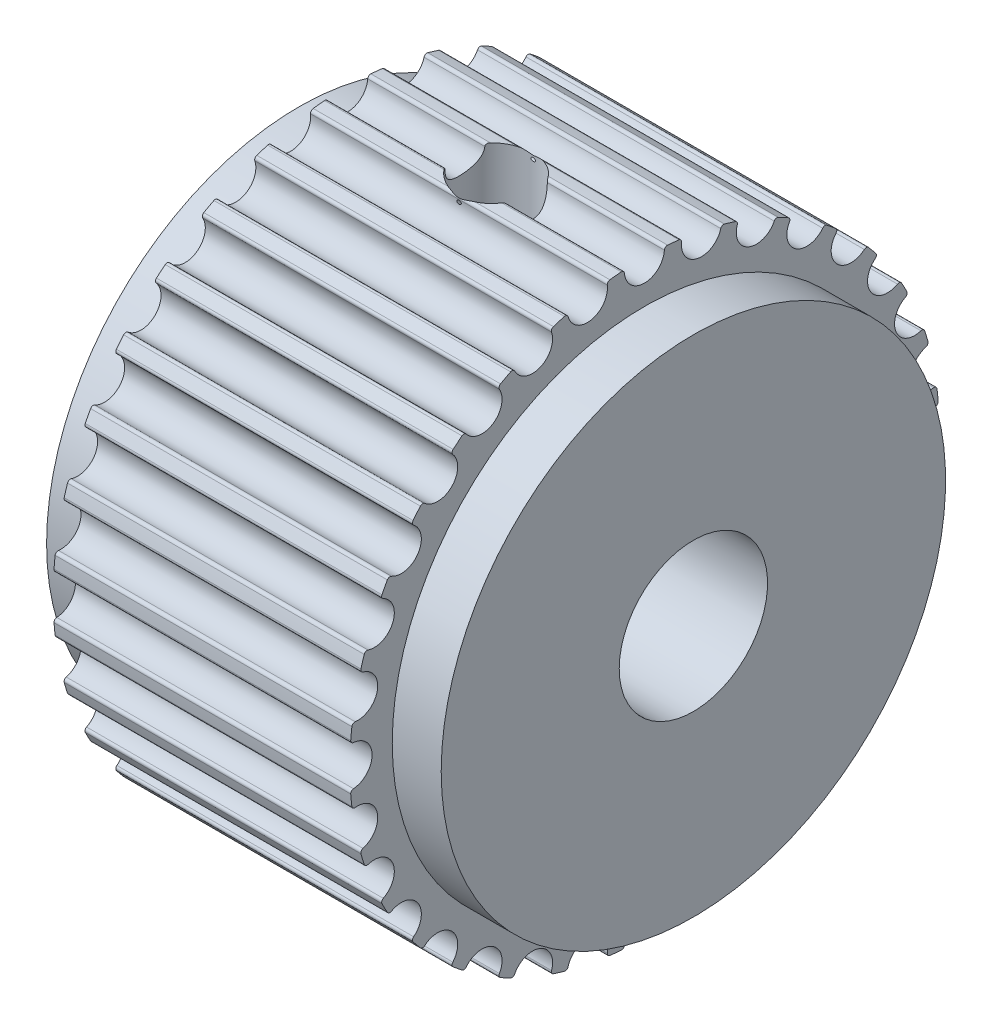
from build123d import *

# Parameters (mm, degrees)
CUT_EXTRUDE1_DEPTH       = 19.246432528
FILLET1_R                = 0.1
CIRPATTERN1_COUNT        = 32
FILLET1_OF_CIRPATTERN1_R = 0.1
TAPPED_HOLE1_REACH       = 42.167
TAPPED_HOLE1_BORE_R      = 1.25
CIRPATTERN2_COUNT        = 2
CIRPATTERN2_ANGLE        = 120


with BuildPart() as part:
    # Sketch1 → Revolve1 (revolve)
    with BuildSketch(Plane.XY, mode=Mode.PRIVATE) as revolve1_sk:
        Polygon((1.65, 9.93), (11.65, 9.93), (11.65, 8.5), (13.3, 8.5), (13.3, 2.5), (0, 2.5), (0, 8.5), (1.65, 8.5), align=None)
    revolve(revolve1_sk.sketch.rotate(Axis((0, 0, 0), (1, 0, 0)), 90), axis=Axis((0, 0, 0), (1, 0, 0)))

    # Sketch2 → Cut-Extrude1 (cut, through all)
    with BuildSketch(Plane(origin=(1.65, 0, 0), x_dir=(0, 0, -1), z_dir=(1, 0, 0))):
        with BuildLine():
            ThreePointArc((0.672980981, 9.90716895), (0, 9.93), (-0.672980981, 9.90716895))
            ThreePointArc((-0.672980981, 9.90716895), (0, 9.18), (0.672980981, 9.90716895))
        make_face()
    cut_extrude1 = extrude(amount=CUT_EXTRUDE1_DEPTH, mode=Mode.SUBTRACT)

    # Fillet1
    fillet1_edges = [part.edges().sort_by_distance(p)[0] for p in [
        (6.65, 9.90716895, 0.672980981),
        (6.65, 9.90716895, -0.672980981),
    ]]
    fillet(fillet1_edges, radius=FILLET1_R)

    # CirPattern1: Cut-Extrude1 ×32 about axis
    cirpattern1_axis = Axis((0, 0, 0), (1, 0, 0))
    for i in range(1, CIRPATTERN1_COUNT):
        add(cut_extrude1.rotate(cirpattern1_axis, i * 360 / CIRPATTERN1_COUNT), mode=Mode.SUBTRACT)

    # Fillet1 of CirPattern1
    fillet1_of_cirpattern1_edges = [part.edges().sort_by_distance(p)[0] for p in [
        (6.65, 9.5855134, 2.592842621),
        (6.65, 9.848097553, 1.272742941),
        (6.65, 8.895491946, 4.413062773),
        (6.65, 9.41056929, 3.169556065),
        (6.65, 7.863621725, 6.063691397),
        (6.65, 8.611398126, 4.944564927),
        (6.65, 6.529556932, 7.481295762),
        (6.65, 7.481295762, 6.529556932),
        (6.65, 4.944564927, 8.611398126),
        (6.65, 6.063691397, 7.863621725),
        (6.65, 3.169556065, 9.41056929),
        (6.65, 4.413062773, 8.895491946),
        (6.65, 1.272742941, 9.848097553),
        (6.65, 2.592842621, 9.5855134),
        (6.65, -0.672980981, 9.90716895),
        (6.65, 0.672980981, 9.90716895),
        (6.65, -2.592842621, 9.5855134),
        (6.65, -1.272742941, 9.848097553),
        (6.65, -4.413062773, 8.895491946),
        (6.65, -3.169556065, 9.41056929),
        (6.65, -6.063691397, 7.863621725),
        (6.65, -4.944564927, 8.611398126),
        (6.65, -7.481295762, 6.529556932),
        (6.65, -6.529556932, 7.481295762),
        (6.65, -8.611398126, 4.944564927),
        (6.65, -7.863621725, 6.063691397),
        (6.65, -9.41056929, 3.169556065),
        (6.65, -8.895491946, 4.413062773),
        (6.65, -9.848097553, 1.272742941),
        (6.65, -9.5855134, 2.592842621),
        (6.65, -9.90716895, -0.672980981),
        (6.65, -9.90716895, 0.672980981),
        (6.65, -9.5855134, -2.592842621),
        (6.65, -9.848097553, -1.272742941),
        (6.65, -8.895491946, -4.413062773),
        (6.65, -9.41056929, -3.169556065),
        (6.65, -7.863621725, -6.063691397),
        (6.65, -8.611398126, -4.944564927),
        (6.65, -6.529556932, -7.481295762),
        (6.65, -7.481295762, -6.529556932),
        (6.65, -4.944564927, -8.611398126),
        (6.65, -6.063691397, -7.863621725),
        (6.65, -3.169556065, -9.41056929),
        (6.65, -4.413062773, -8.895491946),
        (6.65, -1.272742941, -9.848097553),
        (6.65, -2.592842621, -9.5855134),
        (6.65, 0.672980981, -9.90716895),
        (6.65, -0.672980981, -9.90716895),
        (6.65, 2.592842621, -9.5855134),
        (6.65, 1.272742941, -9.848097553),
        (6.65, 4.413062773, -8.895491946),
        (6.65, 3.169556065, -9.41056929),
        (6.65, 6.063691397, -7.863621725),
        (6.65, 4.944564927, -8.611398126),
        (6.65, 7.481295762, -6.529556932),
        (6.65, 6.529556932, -7.481295762),
        (6.65, 8.611398126, -4.944564927),
        (6.65, 7.863621725, -6.063691397),
        (6.65, 9.41056929, -3.169556065),
        (6.65, 8.895491946, -4.413062773),
        (6.65, 9.848097553, -1.272742941),
        (6.65, 9.5855134, -2.592842621),
    ]]
    fillet(fillet1_of_cirpattern1_edges, radius=FILLET1_OF_CIRPATTERN1_R)

    # Tapped Hole1 bore → Tapped Hole1 (cut, up to next)
    with BuildSketch(Plane(origin=(-11.091537855, 9.93, -15.10513819), x_dir=(1, 0, 0), z_dir=(0, 1, 0)), mode=Mode.PRIVATE) as tapped_hole1_sk1:
        with Locations((17.741537855, -15.10513819)):
            Circle(TAPPED_HOLE1_BORE_R)
    tapped_hole1_tool1 = extrude(tapped_hole1_sk1.sketch, amount=-TAPPED_HOLE1_REACH, mode=Mode.PRIVATE) & part.part
    tapped_hole1 = tapped_hole1_tool1.solids().sort_by_distance((6.65, 9.93, 0))[0]
    add(tapped_hole1, mode=Mode.SUBTRACT)

    # CirPattern2: Tapped Hole1; each copy of Tapped Hole1 runs up to whatever stops it at its own place
    cirpattern2_before = part.part  # the part as the pattern finds it: every copy runs up to it
    cirpattern2_tapped_hole1_long = extrude(tapped_hole1_sk1.sketch, amount=-TAPPED_HOLE1_REACH, mode=Mode.PRIVATE)
    cirpattern2_tapped_hole1_tool = cirpattern2_tapped_hole1_long.rotate(Axis((0, 0, 0), (-1, 0, 0)), 1 * CIRPATTERN2_ANGLE / (CIRPATTERN2_COUNT - 1)) & cirpattern2_before
    add(cirpattern2_tapped_hole1_tool.solids().sort_by_distance((6.65, -4.965, -8.599632))[0], mode=Mode.SUBTRACT)


solid = part.part
